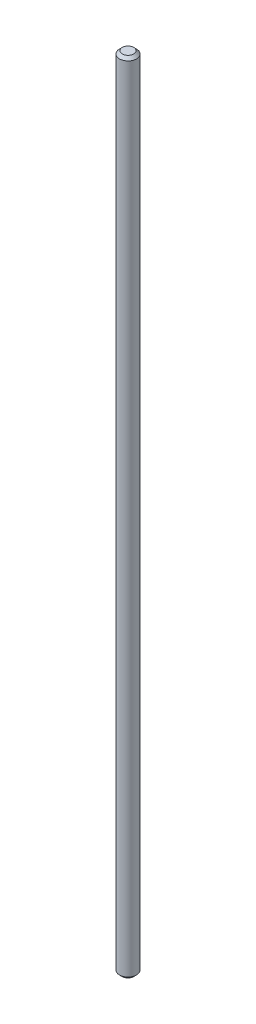
from build123d import *

# Parameters (mm, degrees)
CROQUIS1_R              = 1.5
SALIENTE_EXTRUIR1_DEPTH = 140
CHAFL_N1_SIZE           = 0.5


with BuildPart() as part:
    # Croquis1 → Saliente-Extruir1 (new body)
    with BuildSketch(Plane(origin=(0, 0, 0), x_dir=(1, 0, 0), z_dir=(0, 1, 0))):
        Circle(CROQUIS1_R)
    extrude(amount=SALIENTE_EXTRUIR1_DEPTH)

    # Chaflán1
    chafl_n1_edges = [part.edges().sort_by_distance(p)[0] for p in [
        (-1.5, 0, 0),
        (-1.5, 140, 0),
    ]]
    chamfer(chafl_n1_edges, length=CHAFL_N1_SIZE)


solid = part.part
